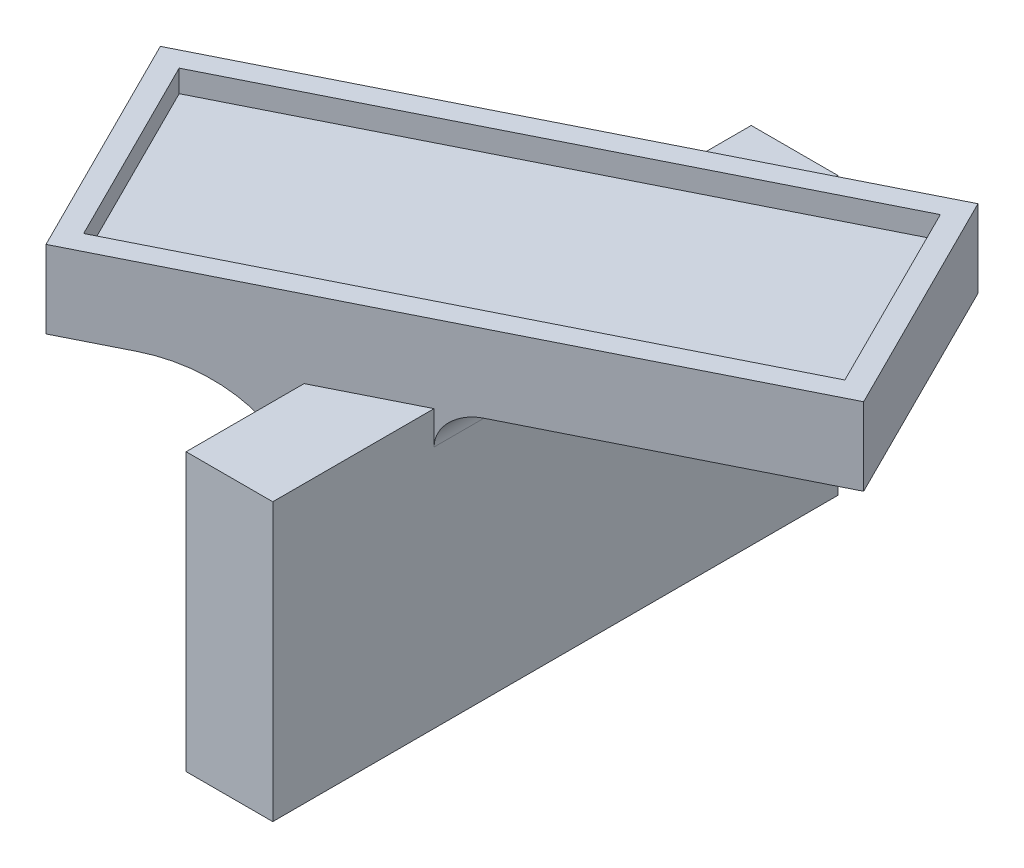
from build123d import *

# Parameters (mm, degrees)
SKETCH1_W           = 7.82
SKETCH1_H           = 51
BOSS_EXTRUDE1_DEPTH = 25
BOSS_EXTRUDE2_DEPTH = 5
BOSS_EXTRUDE3_DEPTH = 2
FILLET1_R           = 10
FILLET2_R           = 3
SKETCH4_W           = 3
SKETCH4_H           = 10
BOSS_EXTRUDE4_DEPTH = 2.5
CHAMFER1_SIZE       = 1


with BuildPart() as part:
    # Sketch1 → Boss-Extrude1 (new body)
    with BuildSketch(Plane(origin=(0, 0, 0), x_dir=(1, 0, 0), z_dir=(0, 1, 0))):
        Rectangle(SKETCH1_W, SKETCH1_H)
    extrude(amount=BOSS_EXTRUDE1_DEPTH)

    # Sketch2 → Boss-Extrude2 (add)
    with BuildSketch(Plane(origin=(0, 25, 0), x_dir=(1, 0, 0), z_dir=(0, 1, 0))):
        Polygon((-19.438138919, -22.615591532), (29.755356576, 1.98115624), (19.438138919, 22.615591532), (-29.755356576, -1.98115624), align=None)
    extrude(amount=BOSS_EXTRUDE2_DEPTH)

    # Sketch3 → Boss-Extrude3 (add)
    with BuildSketch(Plane(origin=(0, 30, 0), x_dir=(1, 0, 0), z_dir=(0, 1, 0))):
        Polygon((-19.438138919, -22.615591532), (29.755356576, 1.98115624), (19.438138919, 22.615591532), (-29.755356576, -1.98115624), align=None)
        Polygon((27.206239081, 2.83086207), (-18.588433089, -20.066474038), (-27.206239081, -2.83086207), (18.588433089, 20.066474038), align=None, mode=Mode.SUBTRACT)
    extrude(amount=BOSS_EXTRUDE3_DEPTH)

    # Fillet1
    fillet1_edges = [part.edges().sort_by_distance(p)[0] for p in [
        (-3.91, 25, 1.955000002),
    ]]
    fillet(fillet1_edges, radius=FILLET1_R)

    # Fillet2
    fillet2_edges = [part.edges().sort_by_distance(p)[0] for p in [
        (3.91, 25, -1.955000002),
    ]]
    fillet(fillet2_edges, radius=FILLET2_R)

    # Sketch4 → Boss-Extrude4 (add)
    with BuildSketch(Plane.ZY.offset(3.91)):
        Rectangle(SKETCH4_W, SKETCH4_H)
    extrude(amount=BOSS_EXTRUDE4_DEPTH)

    # Chamfer1
    chamfer1_edges = [part.edges().sort_by_distance(p)[0] for p in [
        (-3.91, 2.5, 1.5),
        (-3.91, 5, 0),
        (-3.91, 2.5, -1.5),
    ]]
    chamfer(chamfer1_edges, length=CHAMFER1_SIZE)


solid = part.part
